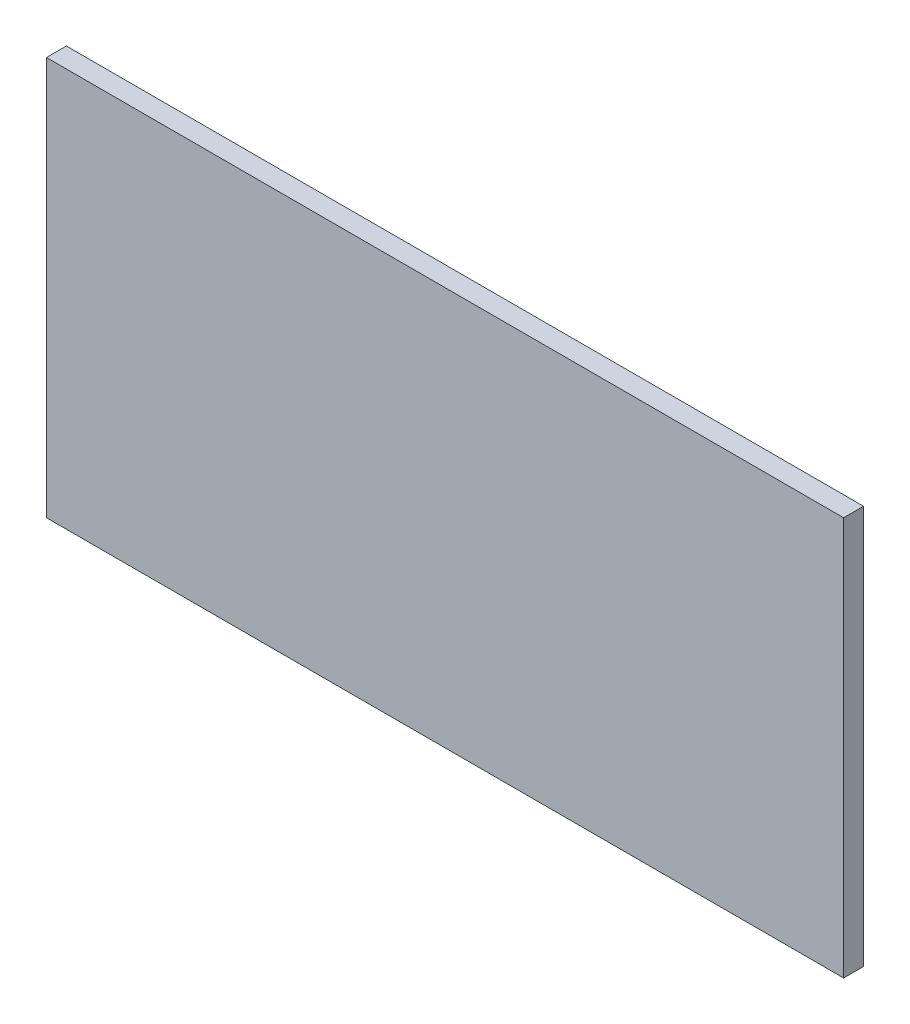
from build123d import *

# Parameters (mm, degrees)
CROQUIS1_W              = 120
CROQUIS1_H              = 60
SALIENTE_EXTRUIR1_DEPTH = 3


with BuildPart() as part:
    # Croquis1 → Saliente-Extruir1 (new body)
    with BuildSketch(Plane.XY):
        Rectangle(CROQUIS1_W, CROQUIS1_H)
    extrude(amount=SALIENTE_EXTRUIR1_DEPTH)


solid = part.part
